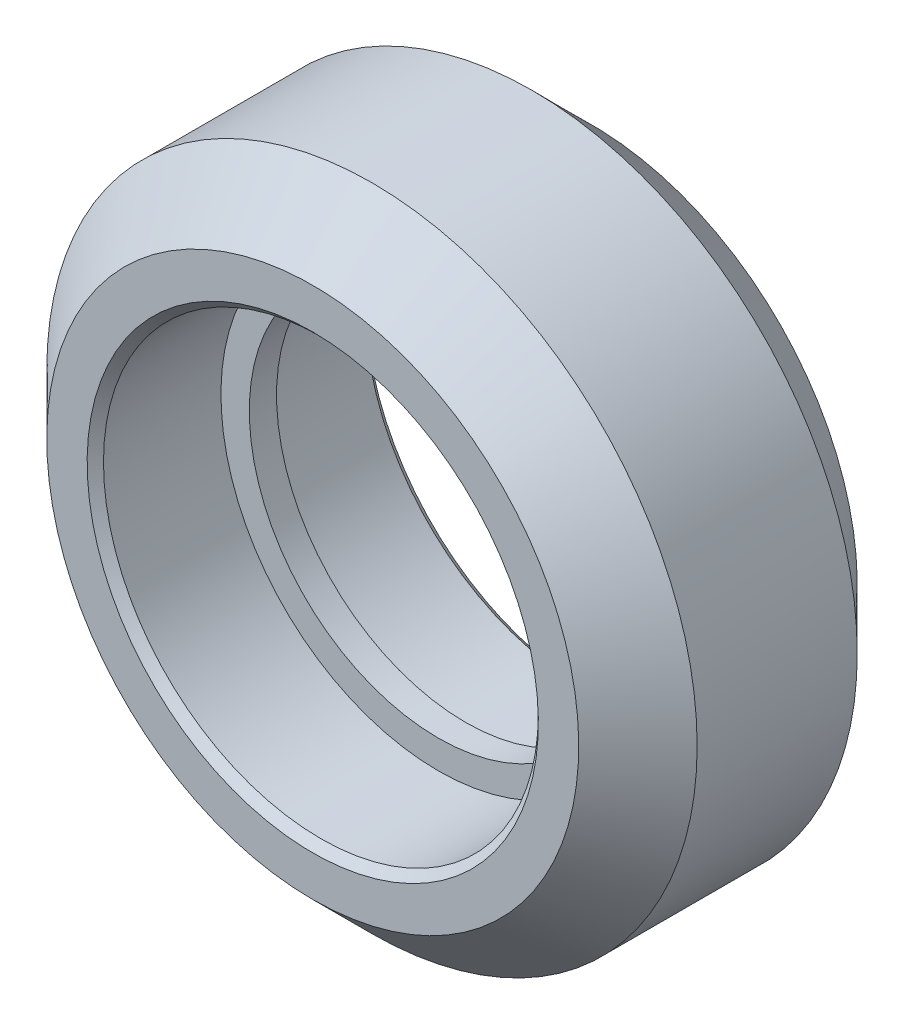
from build123d import *

# Parameters (mm, degrees)
CHAMFER1_SIZE = 0.3


with BuildPart() as part:
    # Sketch1 → Revolve1 (revolve)
    with BuildSketch(Plane(origin=(0, 0, 0), x_dir=(0, 0, -1), z_dir=(1, 0, 0))):
        Polygon((-2.94, 11.945), (2.94, 11.945), (5.115, 9.77), (5.115, 7.987), (0.5, 7.987), (0.5, 6.945), (-0.5, 6.945), (-0.5, 7.987), (-5.115, 7.987), (-5.115, 9.77), align=None)
    revolve(axis=Axis((0, 0, 5.115), (0, 0, -1)))

    # Chamfer1
    chamfer1_edges = [part.edges().sort_by_distance(p)[0] for p in [
        (0, -7.987, 5.115),
        (0, -7.987, -5.115),
    ]]
    chamfer(chamfer1_edges, length=CHAMFER1_SIZE)


solid = part.part
